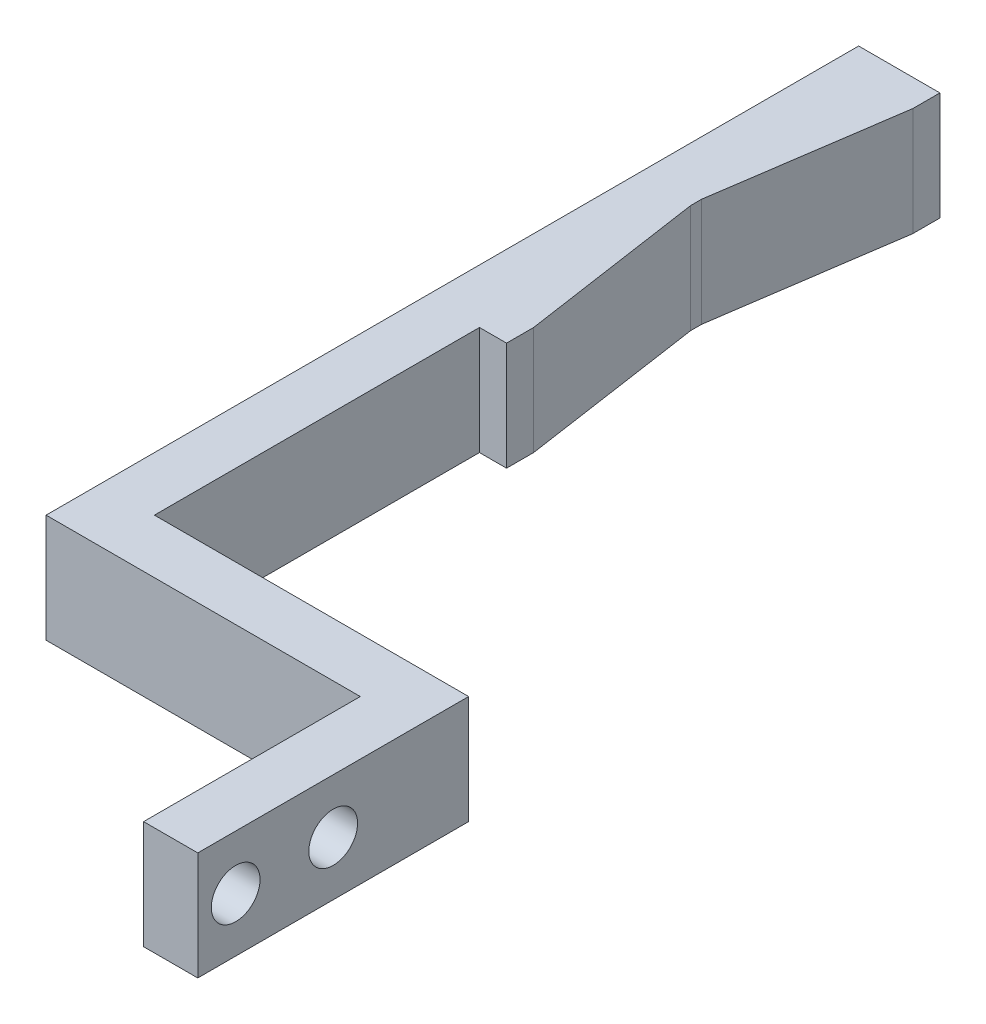
from build123d import *

# Parameters (mm, degrees)
BOSS_EXTRUDE1_DEPTH = 10
SKETCH3_R           = 2.25
CUT_EXTRUDE1_DEPTH  = 35


with BuildPart() as part:
    # Sketch2 → Boss-Extrude1 (new body)
    with BuildSketch(Plane(origin=(0, 0, 0), x_dir=(1, 0, 0), z_dir=(0, 1, 0))):
        Polygon((-5, 0), (0, 0), (0, 25), (-29, 25), (-29, 55), (-26.5, 55), (-26.5, 57.5), (-29, 74.5), (-29, 75.5), (-26.5, 92.5), (-26.5, 95), (-34, 95), (-34, 20), (-5, 20), align=None)
    extrude(amount=BOSS_EXTRUDE1_DEPTH)

    # Sketch3 → Cut-Extrude1 (cut, through all)
    with BuildSketch(Plane(origin=(0, 0, 0), x_dir=(0, 0, -1), z_dir=(1, 0, 0))):
        with Locations((3.5, 5)):
            Circle(SKETCH3_R)
        with Locations((12.5, 5)):
            Circle(SKETCH3_R)
    extrude(amount=-CUT_EXTRUDE1_DEPTH, mode=Mode.SUBTRACT)


solid = part.part
